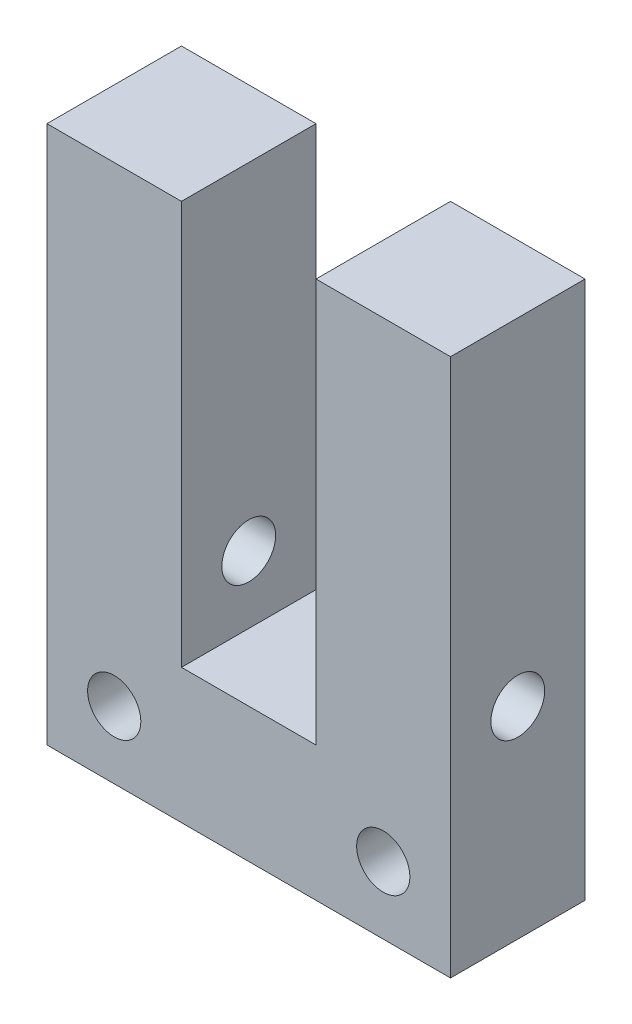
from build123d import *

# Parameters (mm, degrees)
SKETCH1_W        = 19.05
SKETCH1_H        = 25.4
MAIN_BLOCK_DEPTH = 6.35
SKETCH2_W        = 6.35
SKETCH2_H        = 19.05
U_CUT_DEPTH      = 12.7
SKETCH3_R        = 1.25603
BOLT_HOLES_DEPTH = 12.7
SKETCH4_R        = 1.27
PIN_HOLE_DEPTH   = 20.05


with BuildPart() as part:
    # Sketch1 → Main block (new body)
    with BuildSketch(Plane.XY):
        with Locations((9.525, 12.7)):
            Rectangle(SKETCH1_W, SKETCH1_H)
    extrude(amount=MAIN_BLOCK_DEPTH)

    # Sketch2 → U-cut (cut)
    with BuildSketch(Plane.XY.offset(6.35)):
        with Locations((9.525, 15.875)):
            Rectangle(SKETCH2_W, SKETCH2_H)
    extrude(amount=-U_CUT_DEPTH, mode=Mode.SUBTRACT)

    # Sketch3 → Bolt holes (cut)
    with BuildSketch(Plane.XY.offset(6.35)):
        with Locations((3.175, 3.175)):
            Circle(SKETCH3_R)
        with Locations((15.875, 3.175)):
            Circle(SKETCH3_R)
    extrude(amount=-BOLT_HOLES_DEPTH, mode=Mode.SUBTRACT)

    # Sketch4 → Pin hole (cut, through all)
    with BuildSketch(Plane.ZY):
        with Locations((3.175, 9.525)):
            Circle(SKETCH4_R)
    extrude(amount=-PIN_HOLE_DEPTH, mode=Mode.SUBTRACT)


solid = part.part
